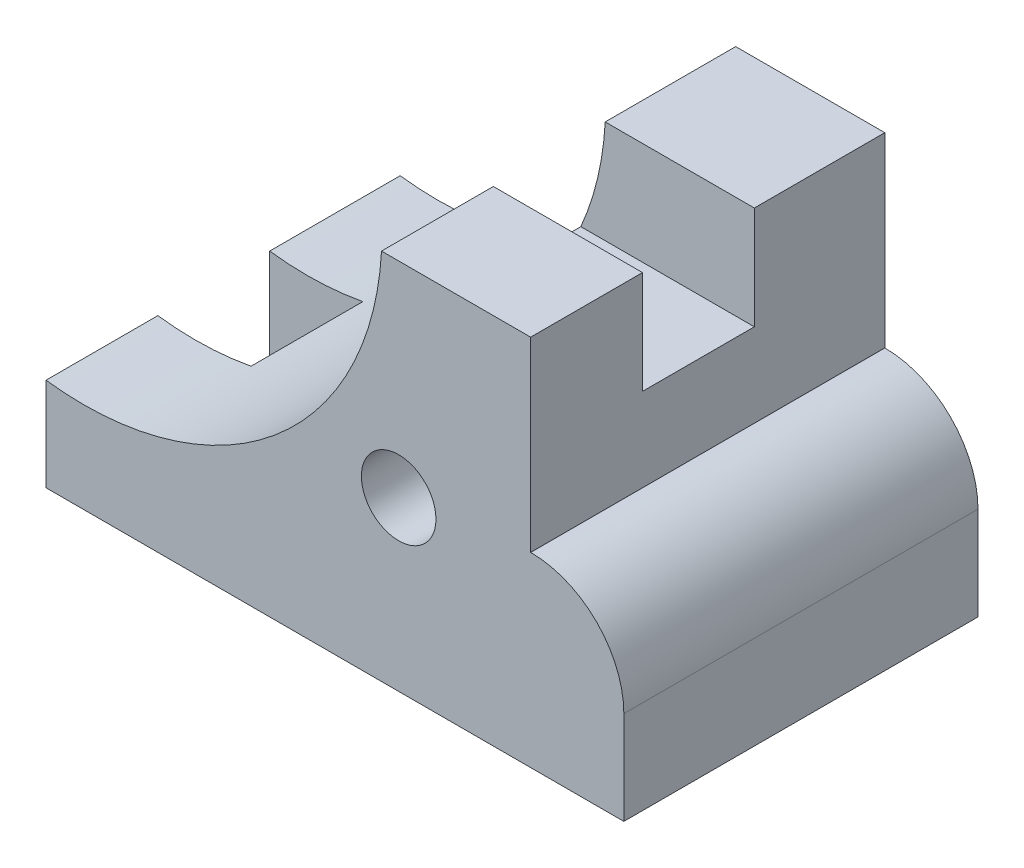
from build123d import *

# Parameters (mm, degrees)
BOSS_EXTRUDE1_DEPTH = 60.325
SKETCH2_W           = 19.05
SKETCH2_H           = 17.526
CUT_EXTRUDE1_DEPTH  = 29.8196
SKETCH3_W           = 15.875
SKETCH3_H           = 19.05
CUT_EXTRUDE2_DEPTH  = 29.8196
SKETCH4_R           = 6.35
CUT_EXTRUDE3_DEPTH  = 60.3504


with BuildPart() as part:
    # Sketch1 → Boss-Extrude1 (new body)
    with BuildSketch(Plane.XY):
        with BuildLine():
            Line((0, 0), (82.55, 0))
            Line((82.55, 0), (98.425, 0))
            Line((98.425, 0), (98.425, 15.9004))
            ThreePointArc((98.425, 15.9004), (93.782759639, 27.107759639), (82.5754, 31.75))
            Line((82.5754, 31.75), (82.55, 31.75))
            Line((82.55, 31.75), (82.55, 63.5))
            Line((82.55, 63.5), (57.15, 63.5))
            ThreePointArc((57.15, 63.5), (38.947337741, 27.240694711), (0, 15.875))
            Line((0, 15.875), (0, 0))
        make_face()
    extrude(amount=-BOSS_EXTRUDE1_DEPTH)

    # Sketch2 → Cut-Extrude1 (cut)
    with BuildSketch(Plane(origin=(82.55, 0, 0), x_dir=(0, 0, -1), z_dir=(1, 0, 0))):
        with Locations((28.575, 54.737)):
            Rectangle(SKETCH2_W, SKETCH2_H)
    extrude(amount=-CUT_EXTRUDE1_DEPTH, mode=Mode.SUBTRACT)

    # Sketch3 → Cut-Extrude2 (cut)
    with BuildSketch(Plane.XZ):
        with Locations((7.9375, -28.575)):
            Rectangle(SKETCH3_W, SKETCH3_H)
    extrude(amount=-CUT_EXTRUDE2_DEPTH, mode=Mode.SUBTRACT)

    # Sketch4 → Cut-Extrude3 (cut)
    with BuildSketch(Plane.XY):
        with Locations((60.071, 28.575)):
            Circle(SKETCH4_R)
    extrude(amount=-CUT_EXTRUDE3_DEPTH, mode=Mode.SUBTRACT)


solid = part.part
